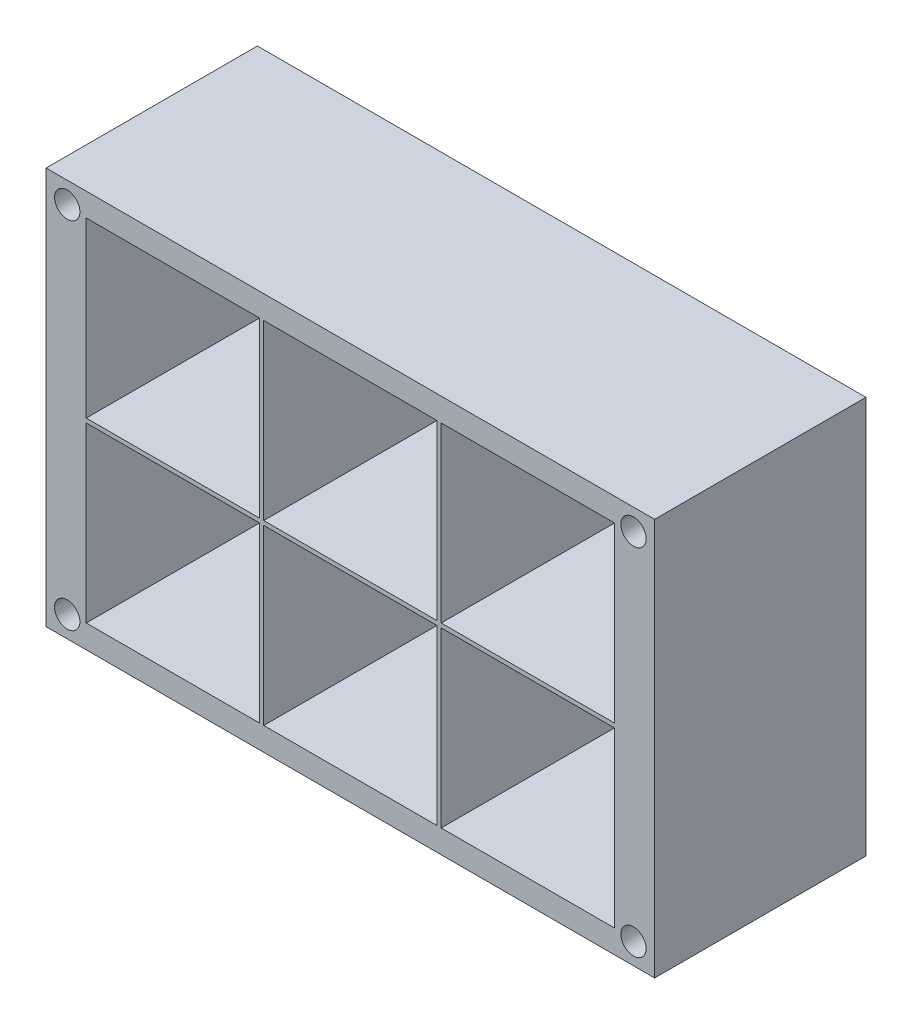
from build123d import *

# Parameters (mm, degrees)
SKETCH_1_W          = 72
SKETCH_1_H          = 47
SKETCH_1_W_2        = 20.5
SKETCH_1_H_2        = 20.5
EXTRUDE_1_DEPTH     = 25
SKETCH_2_R          = 1.5
CUT_EXTRUDE_1_DEPTH = 26


with BuildPart() as part:
    # ｽｹｯﾁ1 → ﾎﾞｽ - 押し出し1 (new body)
    with BuildSketch(Plane.XY):
        with Locations((-49.384838442, 41.173989141)):
            Rectangle(SKETCH_1_W, SKETCH_1_H)
        with Locations((-49.384838442, 30.673989141)):
            Rectangle(SKETCH_1_W_2, SKETCH_1_H_2, mode=Mode.SUBTRACT)
        with Locations((-70.384838442, 30.673989141)):
            Rectangle(SKETCH_1_W_2, SKETCH_1_H_2, mode=Mode.SUBTRACT)
        with Locations((-28.384838442, 30.673989141)):
            Rectangle(SKETCH_1_W_2, SKETCH_1_H_2, mode=Mode.SUBTRACT)
        with Locations((-49.384838442, 51.673989141)):
            Rectangle(SKETCH_1_W_2, SKETCH_1_H_2, mode=Mode.SUBTRACT)
        with Locations((-28.384838442, 51.673989141)):
            Rectangle(SKETCH_1_W_2, SKETCH_1_H_2, mode=Mode.SUBTRACT)
        with Locations((-70.384838442, 51.673989141)):
            Rectangle(SKETCH_1_W_2, SKETCH_1_H_2, mode=Mode.SUBTRACT)
    extrude(amount=EXTRUDE_1_DEPTH)

    # ｽｹｯﾁ2 → ｶｯﾄ - 押し出し1 (cut, through all)
    with BuildSketch(Plane.XY.offset(25)):
        with Locations((-15.884838442, 62.173989141)):
            Circle(SKETCH_2_R)
        with Locations((-82.884838442, 62.173989141)):
            Circle(SKETCH_2_R)
        with Locations((-82.884838442, 20.173989141)):
            Circle(SKETCH_2_R)
        with Locations((-15.884838442, 20.173989141)):
            Circle(SKETCH_2_R)
    extrude(amount=-CUT_EXTRUDE_1_DEPTH, mode=Mode.SUBTRACT)


solid = part.part
